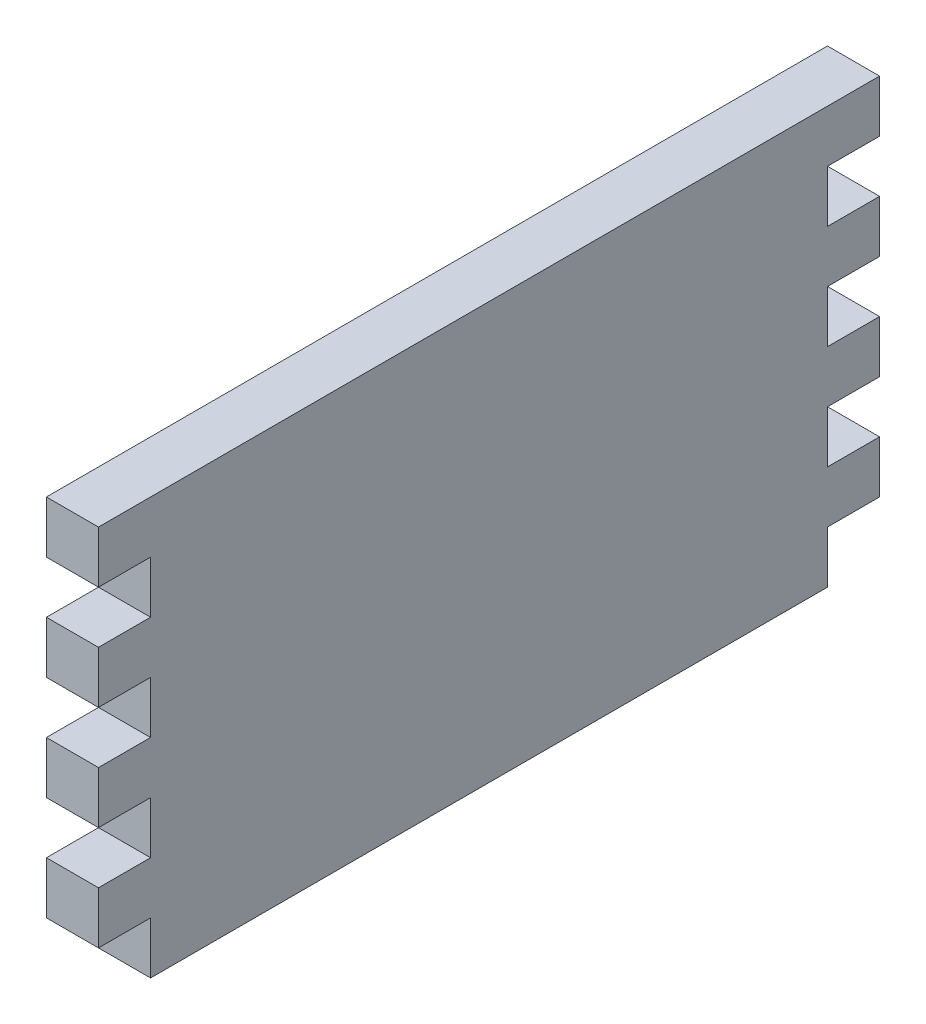
from build123d import *

# Parameters (mm, degrees)
ESQUISSE1_W                = 150
ESQUISSE1_H                = 80
BOSS_EXTRU_1_DEPTH         = 10
ESQUISSE2_W                = 10
ESQUISSE2_H                = 10
ENL_V_MAT_EXTRU_1_DEPTH    = 10
R_P_TITION_LIN_AIRE1_COUNT = 4
R_P_TITION_LIN_AIRE1_PITCH = 20


with BuildPart() as part:
    # Esquisse1 → Boss.-Extru.1 (new body)
    with BuildSketch(Plane(origin=(0, 0, 0), x_dir=(0, 0, -1), z_dir=(1, 0, 0))):
        with Locations((-75, 40)):
            Rectangle(ESQUISSE1_W, ESQUISSE1_H)
    extrude(amount=BOSS_EXTRU_1_DEPTH)

    # Esquisse2 → Enlèv. mat.-Extru.1 (cut)
    with BuildSketch(Plane.ZY):
        with Locations((5, 65)):
            Rectangle(ESQUISSE2_W, ESQUISSE2_H)
        with Locations((145, 65)):
            Rectangle(ESQUISSE2_W, ESQUISSE2_H)
    enl_v_mat_extru_1 = extrude(amount=-ENL_V_MAT_EXTRU_1_DEPTH, mode=Mode.SUBTRACT)

    # Répétition linéaire1: Enlèv. mat.-Extru.1 ×4
    with Locations(*[(0, -i * R_P_TITION_LIN_AIRE1_PITCH, 0) for i in range(1, R_P_TITION_LIN_AIRE1_COUNT)]):
        add(enl_v_mat_extru_1, mode=Mode.SUBTRACT)


solid = part.part
